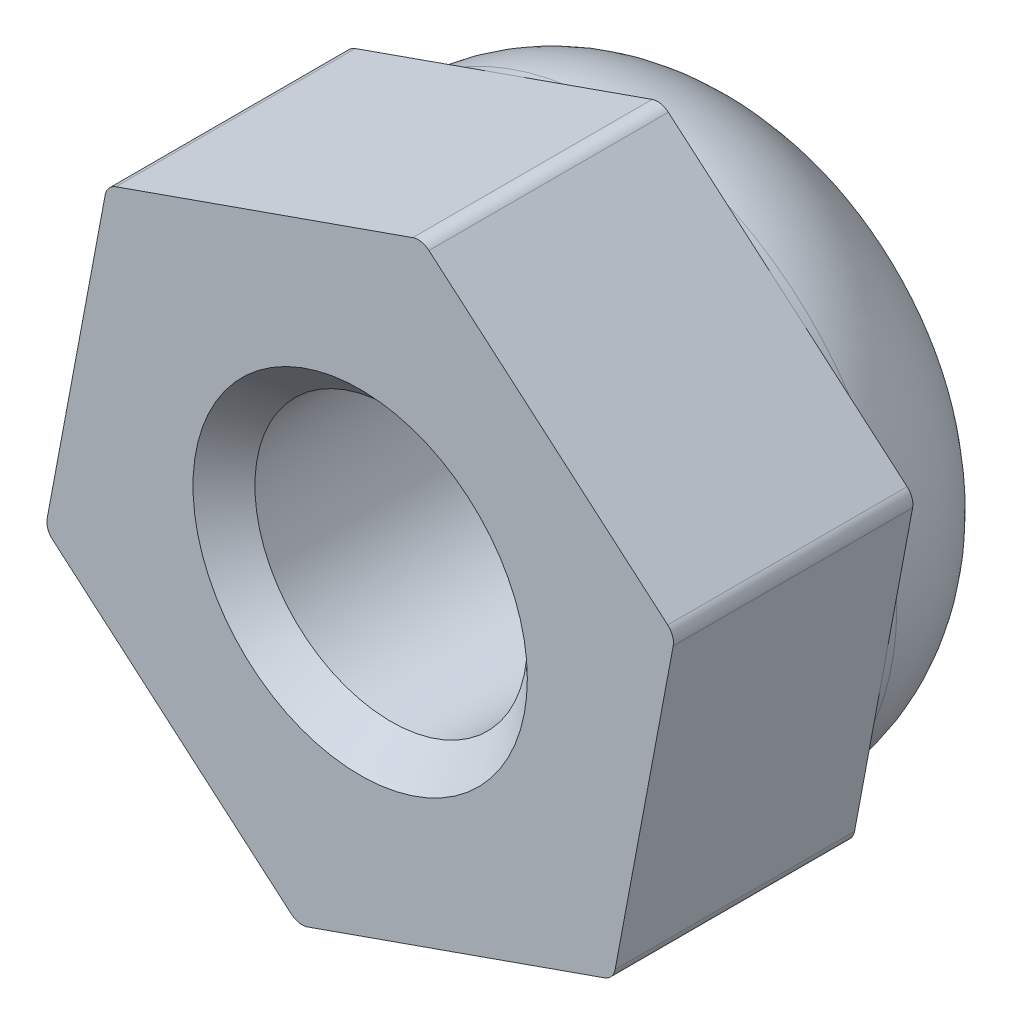
from build123d import *

# Parameters (mm, degrees)
EXTRUDE_1_DEPTH              = 2.9
SKETCH_2_R                   = 3.5
EXTRUDE_3_DEPTH              = 5
FILLET_1_R                   = 2
FILLET_2_R                   = 0.2
HOLE_WIZARD_M4_2_D           = 3.3
HOLE_WIZARD_M4_2_DEPTH       = 10.1
HOLE_WIZARD_M4_2_CSINK_D     = 4.05
HOLE_WIZARD_M4_2_CSINK_ANGLE = 90
HOLE_WIZARD_M4_2_TIP         = 0.991420021


with BuildPart() as part:
    # 草图1 → 凸台-拉伸1 (new body)
    with BuildSketch(Plane.XY):
        Polygon((3.067162176, -2.631700879), (3.812700905, 1.340389922), (0.745538729, 3.972090802), (-3.067162176, 2.631700879), (-3.812700905, -1.340389922), (-0.745538729, -3.972090802), align=None)
    extrude(amount=EXTRUDE_1_DEPTH)

    # 草图2 → 凸台-拉伸3 (add)
    with BuildSketch(Plane.XY.offset(2.9)):
        Circle(SKETCH_2_R)
    extrude(amount=-EXTRUDE_3_DEPTH)

    # 圆角1
    fillet_1_edges = [part.edges().sort_by_distance(p)[0] for p in [
        (-3.5, 0, -2.1),
    ]]
    fillet(fillet_1_edges, radius=FILLET_1_R)

    # 圆角2
    fillet_2_edges = [part.edges().sort_by_distance(p)[0] for p in [
        (-0.745538729, -3.972090802, 1.45),
        (-3.812700905, -1.340389922, 1.45),
        (-3.067162176, 2.631700879, 1.45),
        (0.745538729, 3.972090802, 1.45),
        (3.812700905, 1.340389922, 1.45),
        (3.067162176, -2.631700879, 1.45),
    ]]
    fillet(fillet_2_edges, radius=FILLET_2_R)

    # M4 螺纹孔2
    with Locations(Plane.XY.offset(2.9)):
        with Locations((0, 0)):
            CounterSinkHole(HOLE_WIZARD_M4_2_D / 2, HOLE_WIZARD_M4_2_CSINK_D / 2, depth=HOLE_WIZARD_M4_2_DEPTH, counter_sink_angle=HOLE_WIZARD_M4_2_CSINK_ANGLE)
            with Locations((0, 0, -(HOLE_WIZARD_M4_2_DEPTH + HOLE_WIZARD_M4_2_TIP / 2))):  # 118° drill point
                Cone(0, HOLE_WIZARD_M4_2_D / 2, HOLE_WIZARD_M4_2_TIP, mode=Mode.SUBTRACT)


solid = part.part
